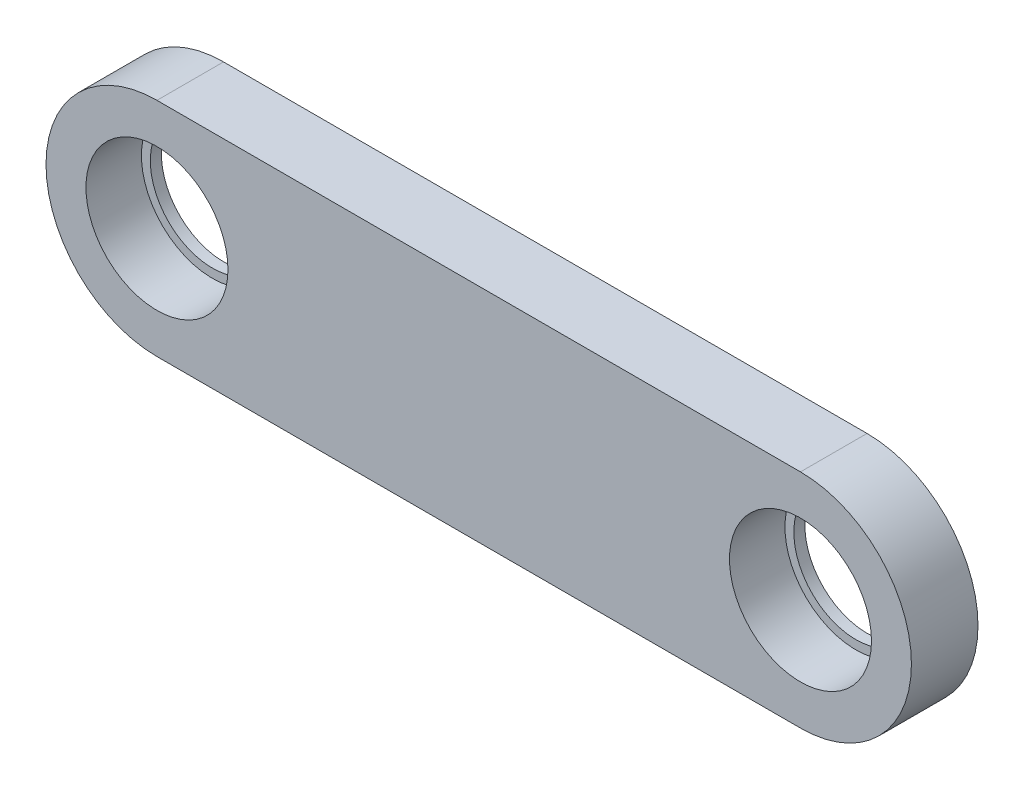
from build123d import *

# Parameters (mm, degrees)
EXTRUDE_1_DEPTH          = 15
SKETCH_2_R               = 16
CUT_EXTRUDE_1_DEPTH      = 12.5
SKETCH_3_R               = 14
CUT_EXTRUDE_2_DEPTH      = 1
CUT_EXTRUDE_2_DEPTH_BACK = 16


with BuildPart() as part:
    # 草图1 → 凸台-拉伸1 (new body)
    with BuildSketch(Plane.XY):
        with BuildLine():
            Line((-72.5, 25), (72.5, 25))
            ThreePointArc((72.5, 25), (97.5, 0), (72.5, -25))
            Line((72.5, -25), (-72.5, -25))
            ThreePointArc((-72.5, -25), (-97.5, 0), (-72.5, 25))
        make_face()
    extrude(amount=EXTRUDE_1_DEPTH)

    # 草图2 → 切除-拉伸1 (cut)
    with BuildSketch(Plane.XY.offset(15)):
        with Locations((-72.5, 0)):
            Circle(SKETCH_2_R)
        with Locations((72.5, 0)):
            Circle(SKETCH_2_R)
    extrude(amount=-CUT_EXTRUDE_1_DEPTH, mode=Mode.SUBTRACT)

    # 草图3 → 切除-拉伸2 (cut, two sides)
    with BuildSketch(Plane.XY.offset(15)) as cut_extrude_2_sk:
        with Locations((-72.5, 0)):
            Circle(SKETCH_3_R)
        with Locations((72.5, 0)):
            Circle(SKETCH_3_R)
    extrude(amount=CUT_EXTRUDE_2_DEPTH, mode=Mode.SUBTRACT)
    extrude(cut_extrude_2_sk.sketch, amount=-CUT_EXTRUDE_2_DEPTH_BACK, mode=Mode.SUBTRACT)


solid = part.part
